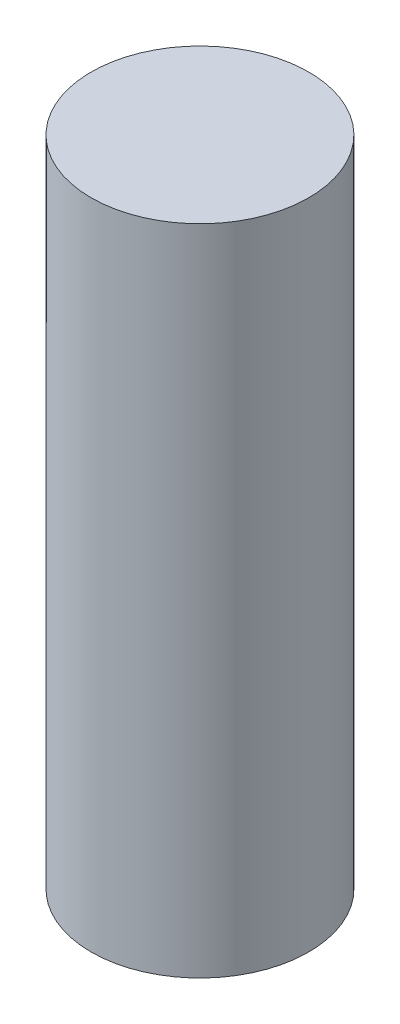
from build123d import *

# Parameters (mm, degrees)
SKETCH1_R           = 10
BOSS_EXTRUDE1_DEPTH = 60


with BuildPart() as part:
    # Sketch1 → Boss-Extrude1 (new body)
    with BuildSketch(Plane(origin=(0, 0, 0), x_dir=(1, 0, 0), z_dir=(0, 1, 0))):
        Circle(SKETCH1_R)
    extrude(amount=BOSS_EXTRUDE1_DEPTH)


solid = part.part
